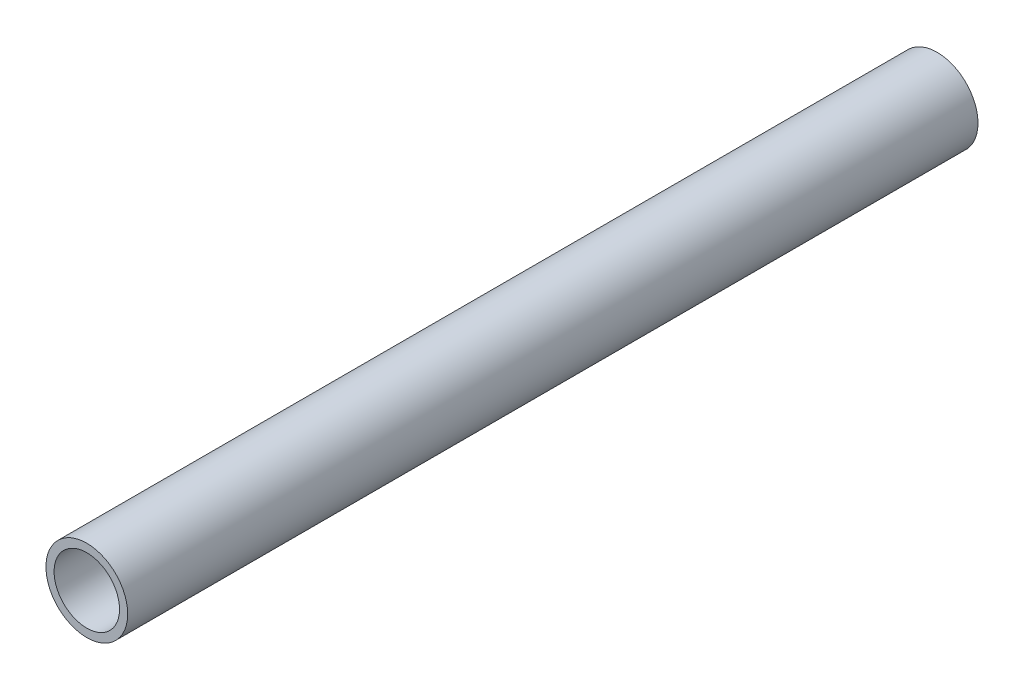
from build123d import *

# Parameters (mm, degrees)
SKETCH1_R           = 1.25
SKETCH1_R_2         = 1
BOSS_EXTRUDE1_DEPTH = 26


with BuildPart() as part:
    # Sketch1 → Boss-Extrude1 (new body)
    with BuildSketch(Plane.XY):
        Circle(SKETCH1_R)
        Circle(SKETCH1_R_2, mode=Mode.SUBTRACT)
    extrude(amount=BOSS_EXTRUDE1_DEPTH)


solid = part.part
